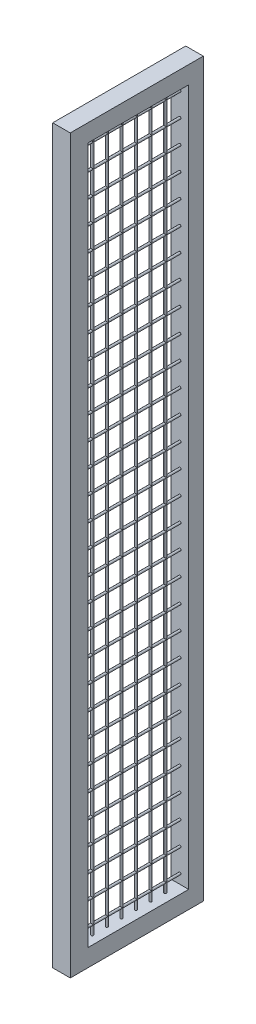
from build123d import *

# Parameters (mm, degrees)
SCHIZZO1_R                      = 3.75
ESTRUSIONE_ESTRUSIONE1_DEPTH    = 900
ESTRUSIONE_ESTRUSIONE1_2_DEPTH  = 900
ESTRUSIONE_ESTRUSIONE1_3_DEPTH  = 900
ESTRUSIONE_ESTRUSIONE1_4_DEPTH  = 900
ESTRUSIONE_ESTRUSIONE1_5_DEPTH  = 900
ESTRUSIONE_ESTRUSIONE1_6_DEPTH  = 900
ESTRUSIONE_ESTRUSIONE1_7_DEPTH  = 900
ESTRUSIONE_ESTRUSIONE1_8_DEPTH  = 900
ESTRUSIONE_ESTRUSIONE1_9_DEPTH  = 900
ESTRUSIONE_ESTRUSIONE1_10_DEPTH = 900
ESTRUSIONE_ESTRUSIONE1_11_DEPTH = 900
ESTRUSIONE_ESTRUSIONE1_12_DEPTH = 900
ESTRUSIONE_ESTRUSIONE1_13_DEPTH = 900
ESTRUSIONE_ESTRUSIONE1_14_DEPTH = 900
ESTRUSIONE_ESTRUSIONE1_15_DEPTH = 900
ESTRUSIONE_ESTRUSIONE1_16_DEPTH = 900
ESTRUSIONE_ESTRUSIONE1_17_DEPTH = 900
ESTRUSIONE_ESTRUSIONE1_18_DEPTH = 900
ESTRUSIONE_ESTRUSIONE1_19_DEPTH = 900
ESTRUSIONE_ESTRUSIONE1_20_DEPTH = 900
ESTRUSIONE_ESTRUSIONE1_21_DEPTH = 900
ESTRUSIONE_ESTRUSIONE1_22_DEPTH = 900
ESTRUSIONE_ESTRUSIONE1_23_DEPTH = 900
ESTRUSIONE_ESTRUSIONE1_24_DEPTH = 900
ESTRUSIONE_ESTRUSIONE1_25_DEPTH = 900
ESTRUSIONE_ESTRUSIONE1_26_DEPTH = 900
ESTRUSIONE_ESTRUSIONE1_27_DEPTH = 900
ESTRUSIONE_ESTRUSIONE1_28_DEPTH = 900
ESTRUSIONE_ESTRUSIONE1_29_DEPTH = 900
ESTRUSIONE_ESTRUSIONE1_30_DEPTH = 900
SCHIZZO1_W                      = 60
SCHIZZO1_H                      = 60
ESTRUSIONE_ESTRUSIONE1_31_DEPTH = 900
ESTRUSIONE_ESTRUSIONE1_32_DEPTH = 900
SCHIZZO2_R                      = 3.75
SCHIZZO2_W                      = 60
SCHIZZO2_H                      = 50
ESTRUSIONE_ESTRUSIONE2_DEPTH    = 2385
SCHIZZO3_W                      = 175.252870159
SCHIZZO3_H                      = 630.396742965
TAGLIO_ESTRUSIONE1_DEPTH        = 2446
TAGLIO_ESTRUSIONE1_DEPTH_BACK   = 61
SCHIZZO4_W                      = 60
SCHIZZO4_H                      = 60
ESTRUSIONE_ESTRUSIONE3_DEPTH    = 2505


with BuildPart() as part:
    # Schizzo1 → Estrusione-Estrusione1 (new body)
    with BuildSketch(Plane(origin=(0, 0, 1950), x_dir=(-1, 0, 0), z_dir=(0, 0, -1))):
        with Locations((0, 2462.5)):
            Circle(SCHIZZO1_R)
    extrude(amount=ESTRUSIONE_ESTRUSIONE1_DEPTH)



with BuildPart() as body_2:
    # Schizzo1 → Estrusione-Estrusione1 2 (new body)
    with BuildSketch(Plane(origin=(0, 0, 1950), x_dir=(-1, 0, 0), z_dir=(0, 0, -1))):
        with Locations((0, 2382.5)):
            Circle(SCHIZZO1_R)
    extrude(amount=ESTRUSIONE_ESTRUSIONE1_2_DEPTH)


with BuildPart() as body_3:
    # Schizzo1 → Estrusione-Estrusione1 3 (new body)
    with BuildSketch(Plane(origin=(0, 0, 1950), x_dir=(-1, 0, 0), z_dir=(0, 0, -1))):
        with Locations((0, 2302.5)):
            Circle(SCHIZZO1_R)
    extrude(amount=ESTRUSIONE_ESTRUSIONE1_3_DEPTH)


with BuildPart() as body_4:
    # Schizzo1 → Estrusione-Estrusione1 4 (new body)
    with BuildSketch(Plane(origin=(0, 0, 1950), x_dir=(-1, 0, 0), z_dir=(0, 0, -1))):
        with Locations((0, 2222.5)):
            Circle(SCHIZZO1_R)
    extrude(amount=ESTRUSIONE_ESTRUSIONE1_4_DEPTH)


with BuildPart() as body_5:
    # Schizzo1 → Estrusione-Estrusione1 5 (new body)
    with BuildSketch(Plane(origin=(0, 0, 1950), x_dir=(-1, 0, 0), z_dir=(0, 0, -1))):
        with Locations((0, 2142.5)):
            Circle(SCHIZZO1_R)
    extrude(amount=ESTRUSIONE_ESTRUSIONE1_5_DEPTH)


with BuildPart() as body_6:
    # Schizzo1 → Estrusione-Estrusione1 6 (new body)
    with BuildSketch(Plane(origin=(0, 0, 1950), x_dir=(-1, 0, 0), z_dir=(0, 0, -1))):
        with Locations((0, 2062.5)):
            Circle(SCHIZZO1_R)
    extrude(amount=ESTRUSIONE_ESTRUSIONE1_6_DEPTH)


with BuildPart() as body_7:
    # Schizzo1 → Estrusione-Estrusione1 7 (new body)
    with BuildSketch(Plane(origin=(0, 0, 1950), x_dir=(-1, 0, 0), z_dir=(0, 0, -1))):
        with Locations((0, 1982.5)):
            Circle(SCHIZZO1_R)
    extrude(amount=ESTRUSIONE_ESTRUSIONE1_7_DEPTH)


with BuildPart() as body_8:
    # Schizzo1 → Estrusione-Estrusione1 8 (new body)
    with BuildSketch(Plane(origin=(0, 0, 1950), x_dir=(-1, 0, 0), z_dir=(0, 0, -1))):
        with Locations((0, 1902.5)):
            Circle(SCHIZZO1_R)
    extrude(amount=ESTRUSIONE_ESTRUSIONE1_8_DEPTH)


with BuildPart() as body_9:
    # Schizzo1 → Estrusione-Estrusione1 9 (new body)
    with BuildSketch(Plane(origin=(0, 0, 1950), x_dir=(-1, 0, 0), z_dir=(0, 0, -1))):
        with Locations((0, 1822.5)):
            Circle(SCHIZZO1_R)
    extrude(amount=ESTRUSIONE_ESTRUSIONE1_9_DEPTH)


with BuildPart() as body_10:
    # Schizzo1 → Estrusione-Estrusione1 10 (new body)
    with BuildSketch(Plane(origin=(0, 0, 1950), x_dir=(-1, 0, 0), z_dir=(0, 0, -1))):
        with Locations((0, 1742.5)):
            Circle(SCHIZZO1_R)
    extrude(amount=ESTRUSIONE_ESTRUSIONE1_10_DEPTH)


with BuildPart() as body_11:
    # Schizzo1 → Estrusione-Estrusione1 11 (new body)
    with BuildSketch(Plane(origin=(0, 0, 1950), x_dir=(-1, 0, 0), z_dir=(0, 0, -1))):
        with Locations((0, 1662.5)):
            Circle(SCHIZZO1_R)
    extrude(amount=ESTRUSIONE_ESTRUSIONE1_11_DEPTH)


with BuildPart() as body_12:
    # Schizzo1 → Estrusione-Estrusione1 12 (new body)
    with BuildSketch(Plane(origin=(0, 0, 1950), x_dir=(-1, 0, 0), z_dir=(0, 0, -1))):
        with Locations((0, 1582.5)):
            Circle(SCHIZZO1_R)
    extrude(amount=ESTRUSIONE_ESTRUSIONE1_12_DEPTH)


with BuildPart() as body_13:
    # Schizzo1 → Estrusione-Estrusione1 13 (new body)
    with BuildSketch(Plane(origin=(0, 0, 1950), x_dir=(-1, 0, 0), z_dir=(0, 0, -1))):
        with Locations((0, 1502.5)):
            Circle(SCHIZZO1_R)
    extrude(amount=ESTRUSIONE_ESTRUSIONE1_13_DEPTH)


with BuildPart() as body_14:
    # Schizzo1 → Estrusione-Estrusione1 14 (new body)
    with BuildSketch(Plane(origin=(0, 0, 1950), x_dir=(-1, 0, 0), z_dir=(0, 0, -1))):
        with Locations((0, 1422.5)):
            Circle(SCHIZZO1_R)
    extrude(amount=ESTRUSIONE_ESTRUSIONE1_14_DEPTH)


with BuildPart() as body_15:
    # Schizzo1 → Estrusione-Estrusione1 15 (new body)
    with BuildSketch(Plane(origin=(0, 0, 1950), x_dir=(-1, 0, 0), z_dir=(0, 0, -1))):
        with Locations((0, 1342.5)):
            Circle(SCHIZZO1_R)
    extrude(amount=ESTRUSIONE_ESTRUSIONE1_15_DEPTH)


with BuildPart() as body_16:
    # Schizzo1 → Estrusione-Estrusione1 16 (new body)
    with BuildSketch(Plane(origin=(0, 0, 1950), x_dir=(-1, 0, 0), z_dir=(0, 0, -1))):
        with Locations((0, 1262.5)):
            Circle(SCHIZZO1_R)
    extrude(amount=ESTRUSIONE_ESTRUSIONE1_16_DEPTH)


with BuildPart() as body_17:
    # Schizzo1 → Estrusione-Estrusione1 17 (new body)
    with BuildSketch(Plane(origin=(0, 0, 1950), x_dir=(-1, 0, 0), z_dir=(0, 0, -1))):
        with Locations((0, 1182.5)):
            Circle(SCHIZZO1_R)
    extrude(amount=ESTRUSIONE_ESTRUSIONE1_17_DEPTH)


with BuildPart() as body_18:
    # Schizzo1 → Estrusione-Estrusione1 18 (new body)
    with BuildSketch(Plane(origin=(0, 0, 1950), x_dir=(-1, 0, 0), z_dir=(0, 0, -1))):
        with Locations((0, 1102.5)):
            Circle(SCHIZZO1_R)
    extrude(amount=ESTRUSIONE_ESTRUSIONE1_18_DEPTH)


with BuildPart() as body_19:
    # Schizzo1 → Estrusione-Estrusione1 19 (new body)
    with BuildSketch(Plane(origin=(0, 0, 1950), x_dir=(-1, 0, 0), z_dir=(0, 0, -1))):
        with Locations((0, 1022.5)):
            Circle(SCHIZZO1_R)
    extrude(amount=ESTRUSIONE_ESTRUSIONE1_19_DEPTH)


with BuildPart() as body_20:
    # Schizzo1 → Estrusione-Estrusione1 20 (new body)
    with BuildSketch(Plane(origin=(0, 0, 1950), x_dir=(-1, 0, 0), z_dir=(0, 0, -1))):
        with Locations((0, 942.5)):
            Circle(SCHIZZO1_R)
    extrude(amount=ESTRUSIONE_ESTRUSIONE1_20_DEPTH)


with BuildPart() as body_21:
    # Schizzo1 → Estrusione-Estrusione1 21 (new body)
    with BuildSketch(Plane(origin=(0, 0, 1950), x_dir=(-1, 0, 0), z_dir=(0, 0, -1))):
        with Locations((0, 862.5)):
            Circle(SCHIZZO1_R)
    extrude(amount=ESTRUSIONE_ESTRUSIONE1_21_DEPTH)


with BuildPart() as body_22:
    # Schizzo1 → Estrusione-Estrusione1 22 (new body)
    with BuildSketch(Plane(origin=(0, 0, 1950), x_dir=(-1, 0, 0), z_dir=(0, 0, -1))):
        with Locations((0, 782.5)):
            Circle(SCHIZZO1_R)
    extrude(amount=ESTRUSIONE_ESTRUSIONE1_22_DEPTH)


with BuildPart() as body_23:
    # Schizzo1 → Estrusione-Estrusione1 23 (new body)
    with BuildSketch(Plane(origin=(0, 0, 1950), x_dir=(-1, 0, 0), z_dir=(0, 0, -1))):
        with Locations((0, 702.5)):
            Circle(SCHIZZO1_R)
    extrude(amount=ESTRUSIONE_ESTRUSIONE1_23_DEPTH)


with BuildPart() as body_24:
    # Schizzo1 → Estrusione-Estrusione1 24 (new body)
    with BuildSketch(Plane(origin=(0, 0, 1950), x_dir=(-1, 0, 0), z_dir=(0, 0, -1))):
        with Locations((0, 622.5)):
            Circle(SCHIZZO1_R)
    extrude(amount=ESTRUSIONE_ESTRUSIONE1_24_DEPTH)


with BuildPart() as body_25:
    # Schizzo1 → Estrusione-Estrusione1 25 (new body)
    with BuildSketch(Plane(origin=(0, 0, 1950), x_dir=(-1, 0, 0), z_dir=(0, 0, -1))):
        with Locations((0, 542.5)):
            Circle(SCHIZZO1_R)
    extrude(amount=ESTRUSIONE_ESTRUSIONE1_25_DEPTH)


with BuildPart() as body_26:
    # Schizzo1 → Estrusione-Estrusione1 26 (new body)
    with BuildSketch(Plane(origin=(0, 0, 1950), x_dir=(-1, 0, 0), z_dir=(0, 0, -1))):
        with Locations((0, 462.5)):
            Circle(SCHIZZO1_R)
    extrude(amount=ESTRUSIONE_ESTRUSIONE1_26_DEPTH)


with BuildPart() as body_27:
    # Schizzo1 → Estrusione-Estrusione1 27 (new body)
    with BuildSketch(Plane(origin=(0, 0, 1950), x_dir=(-1, 0, 0), z_dir=(0, 0, -1))):
        with Locations((0, 382.5)):
            Circle(SCHIZZO1_R)
    extrude(amount=ESTRUSIONE_ESTRUSIONE1_27_DEPTH)


with BuildPart() as body_28:
    # Schizzo1 → Estrusione-Estrusione1 28 (new body)
    with BuildSketch(Plane(origin=(0, 0, 1950), x_dir=(-1, 0, 0), z_dir=(0, 0, -1))):
        with Locations((0, 302.5)):
            Circle(SCHIZZO1_R)
    extrude(amount=ESTRUSIONE_ESTRUSIONE1_28_DEPTH)


with BuildPart() as body_29:
    # Schizzo1 → Estrusione-Estrusione1 29 (new body)
    with BuildSketch(Plane(origin=(0, 0, 1950), x_dir=(-1, 0, 0), z_dir=(0, 0, -1))):
        with Locations((0, 222.5)):
            Circle(SCHIZZO1_R)
    extrude(amount=ESTRUSIONE_ESTRUSIONE1_29_DEPTH)


with BuildPart() as body_30:
    # Schizzo1 → Estrusione-Estrusione1 30 (new body)
    with BuildSketch(Plane(origin=(0, 0, 1950), x_dir=(-1, 0, 0), z_dir=(0, 0, -1))):
        with Locations((0, 142.5)):
            Circle(SCHIZZO1_R)
    extrude(amount=ESTRUSIONE_ESTRUSIONE1_30_DEPTH)


with BuildPart() as body_31:
    # Schizzo1 → Estrusione-Estrusione1 31 (new body)
    with BuildSketch(Plane(origin=(0, 0, 1950), x_dir=(-1, 0, 0), z_dir=(0, 0, -1))):
        with Locations((0, 80)):
            Rectangle(SCHIZZO1_W, SCHIZZO1_H)
    extrude(amount=ESTRUSIONE_ESTRUSIONE1_31_DEPTH)


with BuildPart() as body_32:
    # Schizzo1 → Estrusione-Estrusione1 32 (new body)
    with BuildSketch(Plane(origin=(0, 0, 1950), x_dir=(-1, 0, 0), z_dir=(0, 0, -1))):
        with Locations((0, 2525)):
            Rectangle(SCHIZZO1_W, SCHIZZO1_H)
    extrude(amount=ESTRUSIONE_ESTRUSIONE1_32_DEPTH)


with BuildPart() as part_1:
    add(part.part)

    add(body_2.part)  # Estrusione-Estrusione2 merges body 2

    add(body_3.part)  # Estrusione-Estrusione2 merges body 3

    add(body_4.part)  # Estrusione-Estrusione2 merges body 4

    add(body_5.part)  # Estrusione-Estrusione2 merges body 5

    add(body_6.part)  # Estrusione-Estrusione2 merges body 6

    add(body_7.part)  # Estrusione-Estrusione2 merges body 7

    add(body_8.part)  # Estrusione-Estrusione2 merges body 8

    add(body_9.part)  # Estrusione-Estrusione2 merges body 9

    add(body_10.part)  # Estrusione-Estrusione2 merges body 10

    add(body_11.part)  # Estrusione-Estrusione2 merges body 11

    add(body_12.part)  # Estrusione-Estrusione2 merges body 12

    add(body_13.part)  # Estrusione-Estrusione2 merges body 13

    add(body_14.part)  # Estrusione-Estrusione2 merges body 14

    add(body_15.part)  # Estrusione-Estrusione2 merges body 15

    add(body_16.part)  # Estrusione-Estrusione2 merges body 16

    add(body_17.part)  # Estrusione-Estrusione2 merges body 17

    add(body_18.part)  # Estrusione-Estrusione2 merges body 18

    add(body_19.part)  # Estrusione-Estrusione2 merges body 19

    add(body_20.part)  # Estrusione-Estrusione2 merges body 20

    add(body_21.part)  # Estrusione-Estrusione2 merges body 21

    add(body_22.part)  # Estrusione-Estrusione2 merges body 22

    add(body_23.part)  # Estrusione-Estrusione2 merges body 23

    add(body_24.part)  # Estrusione-Estrusione2 merges body 24

    add(body_25.part)  # Estrusione-Estrusione2 merges body 25

    add(body_26.part)  # Estrusione-Estrusione2 merges body 26

    add(body_27.part)  # Estrusione-Estrusione2 merges body 27

    add(body_28.part)  # Estrusione-Estrusione2 merges body 28

    add(body_29.part)  # Estrusione-Estrusione2 merges body 29

    add(body_30.part)  # Estrusione-Estrusione2 merges body 30

    add(body_31.part)  # Estrusione-Estrusione2 merges body 31

    add(body_32.part)  # Estrusione-Estrusione2 merges body 32
    # Schizzo2 → Estrusione-Estrusione2 (add)
    with BuildSketch(Plane(origin=(0, 110, 0), x_dir=(1, 0, 0), z_dir=(0, 1, 0))):
        with Locations((0, -1850)):
            Circle(SCHIZZO2_R)
        with Locations((0, -1800)):
            Circle(SCHIZZO2_R)
        with Locations((0, -1750)):
            Circle(SCHIZZO2_R)
        with Locations((0, -1700)):
            Circle(SCHIZZO2_R)
        with Locations((0, -1650)):
            Circle(SCHIZZO2_R)
        with Locations((0, -1600)):
            Circle(SCHIZZO2_R)
        with Locations((0, -1550)):
            Circle(SCHIZZO2_R)
        with Locations((0, -1500)):
            Circle(SCHIZZO2_R)
        with Locations((0, -1450)):
            Circle(SCHIZZO2_R)
        with Locations((0, -1400)):
            Circle(SCHIZZO2_R)
        with Locations((0, -1350)):
            Circle(SCHIZZO2_R)
        with Locations((0, -1300)):
            Circle(SCHIZZO2_R)
        with Locations((0, -1250)):
            Circle(SCHIZZO2_R)
        with Locations((0, -1200)):
            Circle(SCHIZZO2_R)
        with Locations((0, -1150)):
            Circle(SCHIZZO2_R)
        with Locations((0, -1075)):
            Rectangle(SCHIZZO2_W, SCHIZZO2_H)
        with Locations((0, -1925)):
            Rectangle(SCHIZZO2_W, SCHIZZO2_H)
    extrude(amount=ESTRUSIONE_ESTRUSIONE2_DEPTH)

    # Schizzo3 → Taglio-Estrusione1 (cut, two sides)
    with BuildSketch(Plane(origin=(0, 110, 0), x_dir=(1, 0, 0), z_dir=(0, 1, 0))) as taglio_estrusione1_sk:
        with Locations((13.455558336, -1760.47689569)):
            Rectangle(SCHIZZO3_W, SCHIZZO3_H)
    extrude(amount=TAGLIO_ESTRUSIONE1_DEPTH, mode=Mode.SUBTRACT)
    extrude(taglio_estrusione1_sk.sketch, amount=-TAGLIO_ESTRUSIONE1_DEPTH_BACK, mode=Mode.SUBTRACT)

    # Schizzo4 → Estrusione-Estrusione3 (add)
    with BuildSketch(Plane(origin=(0, 2555, 0), x_dir=(1, 0, 0), z_dir=(0, 1, 0))):
        with Locations((0, -1475.278524208)):
            Rectangle(SCHIZZO4_W, SCHIZZO4_H)
    extrude(amount=-ESTRUSIONE_ESTRUSIONE3_DEPTH)


solid = part_1.part
